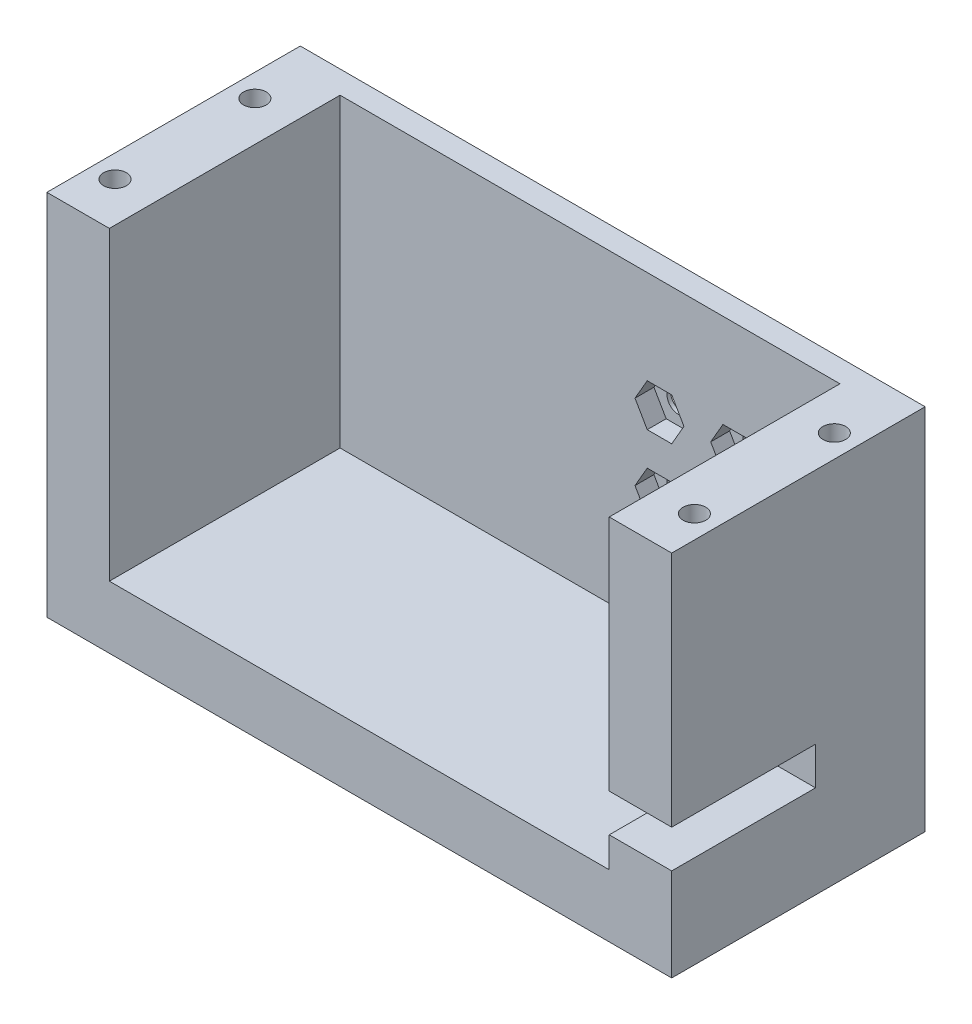
from build123d import *

# Parameters (mm, degrees)
EXTRUDE_1_DEPTH     = 30.48
SKETCH_4_R          = 3.302
EXTRUDE_2_DEPTH     = 6.12463
SKETCH_5_W          = 82.55
SKETCH_5_H          = 48.620400001
EXTRUDE_3_DEPTH     = 3
SKETCH_6_R          = 1.5
CUT_EXTRUDE_1_DEPTH = 3
SKETCH_7_R          = 1.5
CUT_EXTRUDE_2_DEPTH = 2.5
SKETCH_8_R          = 1.5
CUT_EXTRUDE_3_DEPTH = 10
SKETCH_9_W          = 8.255
SKETCH_9_H          = 5
CUT_EXTRUDE_4_DEPTH = 19


with BuildPart() as part:
    # 스케치3 → 보스-돌출1 (new body)
    with BuildSketch(Plane.XY):
        Polygon((21517.522317655, 8422.852866974), (21525.777317655, 8422.852866974), (21525.777317655, 8382.487466973), (21591.817317655, 8382.487466973), (21591.817317655, 8422.852866974), (21600.072317655, 8422.852866974), (21600.072317655, 8374.232466973), (21517.522317655, 8374.232466973), align=None)
    extrude(amount=EXTRUDE_1_DEPTH)

    # 스케치4 → 보스-돌출2 (add)
    with BuildSketch(Plane(origin=(0, 8374.232466973, 0), x_dir=(-1, 0, 0), z_dir=(0, -1, 0))):
        with Locations((-21576.717457655, -15.24)):
            Circle(SKETCH_4_R)
    extrude(amount=EXTRUDE_2_DEPTH)

    # 스케치5 → 보스-돌출3 (add)
    with BuildSketch(Plane(origin=(0, 0, 0), x_dir=(-1, 0, 0), z_dir=(0, 0, -1))):
        with Locations((-21558.797317655, 8398.542666974)):
            Rectangle(SKETCH_5_W, SKETCH_5_H)
    extrude(amount=EXTRUDE_3_DEPTH)

    # 스케치6 → 컷-돌출1 (cut)
    with BuildSketch(Plane.XY):
        with Locations((21577.97657564, 8407.672466973)):
            Circle(SKETCH_6_R)
        with Locations((21567.97657564, 8407.672466973)):
            Circle(SKETCH_6_R)
        with Locations((21567.97657564, 8397.672466973)):
            Circle(SKETCH_6_R)
        with Locations((21577.97657564, 8397.672466973)):
            Circle(SKETCH_6_R)
    extrude(amount=-CUT_EXTRUDE_1_DEPTH, mode=Mode.SUBTRACT)

    # 스케치7 → 컷-돌출2 (cut)
    with BuildSketch(Plane.XY):
        Polygon((21569.593155483, 8410.472467064), (21566.359995798, 8410.472467064), (21564.743415955, 8407.672466973), (21566.359995798, 8404.872466883), (21569.593155483, 8404.872466883), (21571.209735325, 8407.672466973), align=None)
        with Locations((21567.97657564, 8407.672466973)):
            Circle(SKETCH_7_R, mode=Mode.SUBTRACT)
        Polygon((21569.593155483, 8400.472467064), (21566.359995798, 8400.472467064), (21564.743415955, 8397.672466973), (21566.359995798, 8394.872466883), (21569.593155483, 8394.872466883), (21571.209735325, 8397.672466973), align=None)
        with Locations((21567.97657564, 8397.672466973)):
            Circle(SKETCH_7_R, mode=Mode.SUBTRACT)
        Polygon((21579.593155483, 8400.472467064), (21576.359995798, 8400.472467064), (21574.743415955, 8397.672466973), (21576.359995798, 8394.872466883), (21579.593155483, 8394.872466883), (21581.209735325, 8397.672466973), align=None)
        with Locations((21577.97657564, 8397.672466973)):
            Circle(SKETCH_7_R, mode=Mode.SUBTRACT)
        Polygon((21579.593155483, 8410.472467064), (21576.359995798, 8410.472467064), (21574.743415955, 8407.672466973), (21576.359995798, 8404.872466883), (21579.593155483, 8404.872466883), (21581.209735325, 8407.672466973), align=None)
        with Locations((21577.97657564, 8407.672466973)):
            Circle(SKETCH_7_R, mode=Mode.SUBTRACT)
    extrude(amount=-CUT_EXTRUDE_2_DEPTH, mode=Mode.SUBTRACT)

    # 스케치8 → 컷-돌출3 (cut)
    with BuildSketch(Plane(origin=(0, 8422.852866974, 0), x_dir=(1, 0, 0), z_dir=(0, 1, 0))):
        with Locations((21597.072317655, -6)):
            Circle(SKETCH_8_R)
        with Locations((21597.072317655, -24.48)):
            Circle(SKETCH_8_R)
        with Locations((21520.522317655, -24.48)):
            Circle(SKETCH_8_R)
        with Locations((21520.522317655, -6)):
            Circle(SKETCH_8_R)
    extrude(amount=-CUT_EXTRUDE_3_DEPTH, mode=Mode.SUBTRACT)

    # 스케치9 → 컷-돌출4 (cut)
    with BuildSketch(Plane.XY.offset(30.48)):
        with Locations((21595.944817655, 8388.987466973)):
            Rectangle(SKETCH_9_W, SKETCH_9_H)
    extrude(amount=-CUT_EXTRUDE_4_DEPTH, mode=Mode.SUBTRACT)


solid = part.part
